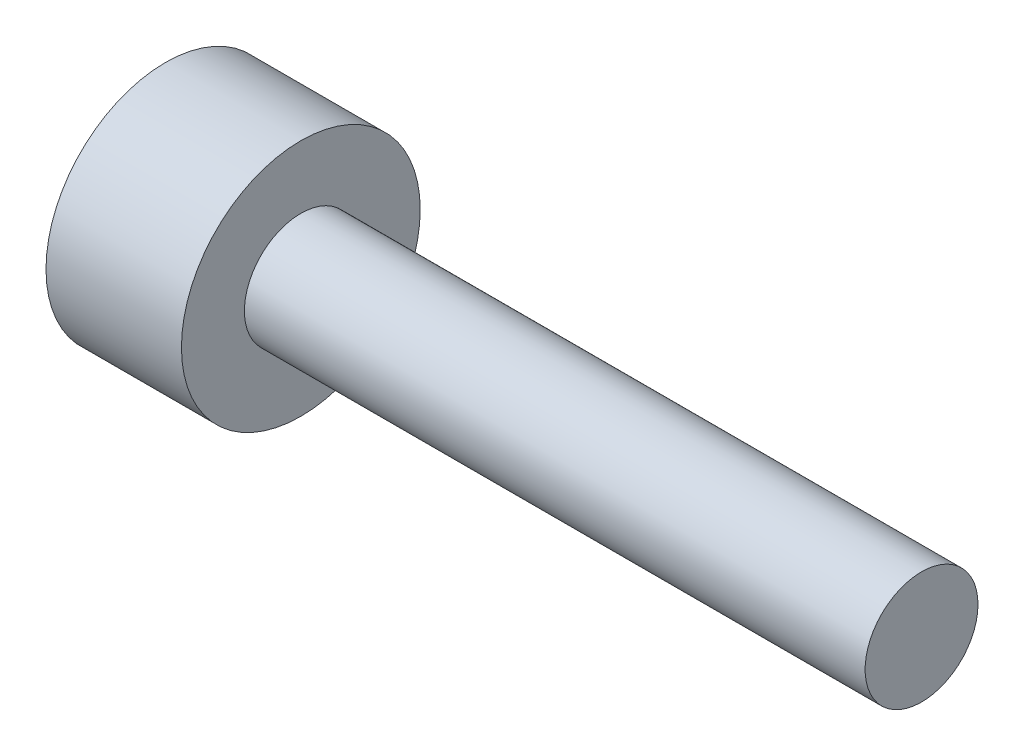
from build123d import *

# Parameters (mm, degrees)
SKETCH1_R           = 0.125
BOSS_EXTRUDE1_DEPTH = 1.375
SKETCH2_R           = 0.264451341
BOSS_EXTRUDE2_DEPTH = 0.3
CUT_EXTRUDE1_DEPTH  = 0.2
SKETCH4_R           = 0.18
CUT_EXTRUDE2_DEPTH  = 0.1
CUT_EXTRUDE2_TAPER  = 60


with BuildPart() as part:
    # Sketch1 → Boss-Extrude1 (new body)
    with BuildSketch(Plane(origin=(0, 0, 0), x_dir=(0, 0, -1), z_dir=(1, 0, 0))):
        Circle(SKETCH1_R)
    extrude(amount=BOSS_EXTRUDE1_DEPTH)

    # Sketch2 → Boss-Extrude2 (add)
    with BuildSketch(Plane.ZY):
        Circle(SKETCH2_R)
    extrude(amount=BOSS_EXTRUDE2_DEPTH)

    # Sketch3 → Cut-Extrude1 (cut)
    with BuildSketch(Plane.ZY.offset(0.3)):
        Polygon((0, 0.207846097), (-0.18, 0.103923048), (-0.18, -0.103923048), (0, -0.207846097), (0.18, -0.103923048), (0.18, 0.103923048), align=None)
    extrude(amount=-CUT_EXTRUDE1_DEPTH, mode=Mode.SUBTRACT)

    # Sketch4 → Cut-Extrude2 (cut)
    with BuildSketch(Plane.ZY.offset(0.1)):
        Circle(SKETCH4_R)
    extrude(amount=-CUT_EXTRUDE2_DEPTH, taper=CUT_EXTRUDE2_TAPER, mode=Mode.SUBTRACT)


solid = part.part
